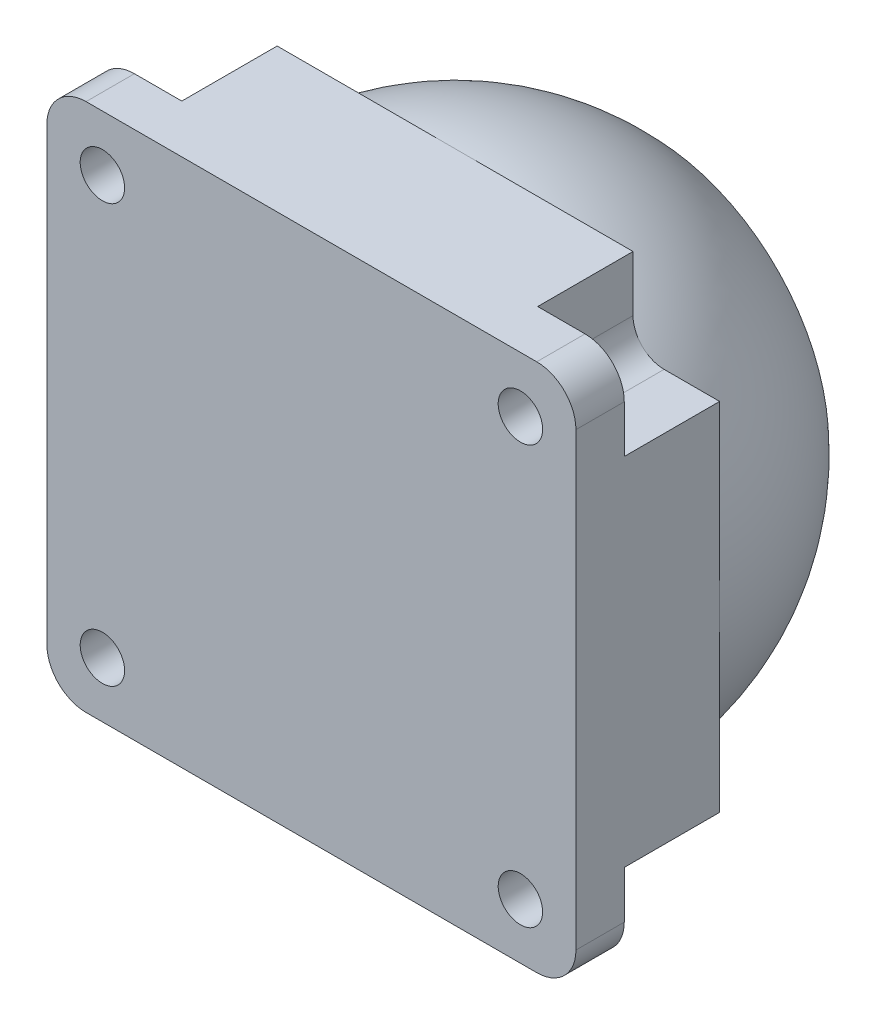
from build123d import *

# Parameters (mm, degrees)
SKETCH_1_W          = 40.5
SKETCH_1_H          = 40.5
EXTRUDE_1_DEPTH     = 11
HOLE_WIZARD_M31_D   = 3.4
SKETCH_7_W          = 40.5
SKETCH_7_H          = 40.5
CUT_EXTRUDE_1_DEPTH = 11
CUT_EXTRUDE_2_DEPTH = 7.3
FILLET_1_R          = 3


with BuildPart() as part:
    # Эскиз1 → Бобышка-Вытянуть1 (new body)
    with BuildSketch(Plane.XY):
        Rectangle(SKETCH_1_W, SKETCH_1_H)
    extrude(amount=EXTRUDE_1_DEPTH)

    # Отверстие с зазором M31 (through all)
    with Locations(Plane.XY.offset(11)):
        with Locations((-16, 16), (16, 16), (16, -16), (-16, -16)):
            Hole(HOLE_WIZARD_M31_D / 2)

    # Эскиз6 → Повернуть1 (revolve)
    with BuildSketch(Plane(origin=(0, 0, 0), x_dir=(-1, 0, 0), z_dir=(0, -1, 0))):
        with BuildLine():
            Line((20.25, 0), (0, 0))
            Line((0, 0), (0, 20.25))
            ThreePointArc((0, 20.25), (14.318912319, 14.318912319), (20.25, 0))
        make_face()
    revolve(axis=Axis((0, 0, 0), (0, 0, -1)))

    # Эскиз7 → Вырез-Вытянуть1 (cut)
    with BuildSketch(Plane(origin=(0, 0, -15), x_dir=(-1, 0, 0), z_dir=(0, 0, -1))):
        Rectangle(SKETCH_7_W, SKETCH_7_H)
    extrude(amount=CUT_EXTRUDE_1_DEPTH, mode=Mode.SUBTRACT)

    # Эскиз9 → Вырез-Вытянуть2 (cut)
    with BuildSketch(Plane(origin=(0, 0, 0), x_dir=(-1, 0, 0), z_dir=(0, 0, -1))):
        with BuildLine():
            Line((-20.25, 20.25), (-13.622583002, 20.25))
            Line((-13.622583002, 20.25), (-13.622583002, 16))
            ThreePointArc((-13.622583002, 16), (-14.318912319, 14.318912319), (-16, 13.622583002))
            Line((-16, 13.622583002), (-20.25, 13.622583002))
            Line((-20.25, 13.622583002), (-20.25, 20.25))
        make_face()
        with BuildLine():
            Line((20.25, 20.25), (20.25, 13.622583002))
            Line((20.25, 13.622583002), (16, 13.622583002))
            ThreePointArc((16, 13.622583002), (14.318912319, 14.318912319), (13.622583002, 16))
            Line((13.622583002, 16), (13.622583002, 20.25))
            Line((13.622583002, 20.25), (20.25, 20.25))
        make_face()
        with BuildLine():
            Line((20.25, -20.25), (13.622583002, -20.25))
            Line((13.622583002, -20.25), (13.622583002, -16))
            ThreePointArc((13.622583002, -16), (14.318912319, -14.318912319), (16, -13.622583002))
            Line((16, -13.622583002), (20.25, -13.622583002))
            Line((20.25, -13.622583002), (20.25, -20.25))
        make_face()
        with BuildLine():
            Line((-20.25, -20.25), (-20.25, -13.622583002))
            Line((-20.25, -13.622583002), (-16, -13.622583002))
            ThreePointArc((-16, -13.622583002), (-14.318912319, -14.318912319), (-13.622583002, -16))
            Line((-13.622583002, -16), (-13.622583002, -20.25))
            Line((-13.622583002, -20.25), (-20.25, -20.25))
        make_face()
    extrude(amount=-CUT_EXTRUDE_2_DEPTH, mode=Mode.SUBTRACT)

    # Скругление1
    fillet_1_edges = [part.edges().sort_by_distance(p)[0] for p in [
        (20.25, -20.25, 9.15),
        (-20.25, -20.25, 9.15),
        (-20.25, 20.25, 9.15),
        (20.25, 20.25, 9.15),
    ]]
    fillet(fillet_1_edges, radius=FILLET_1_R)


solid = part.part
